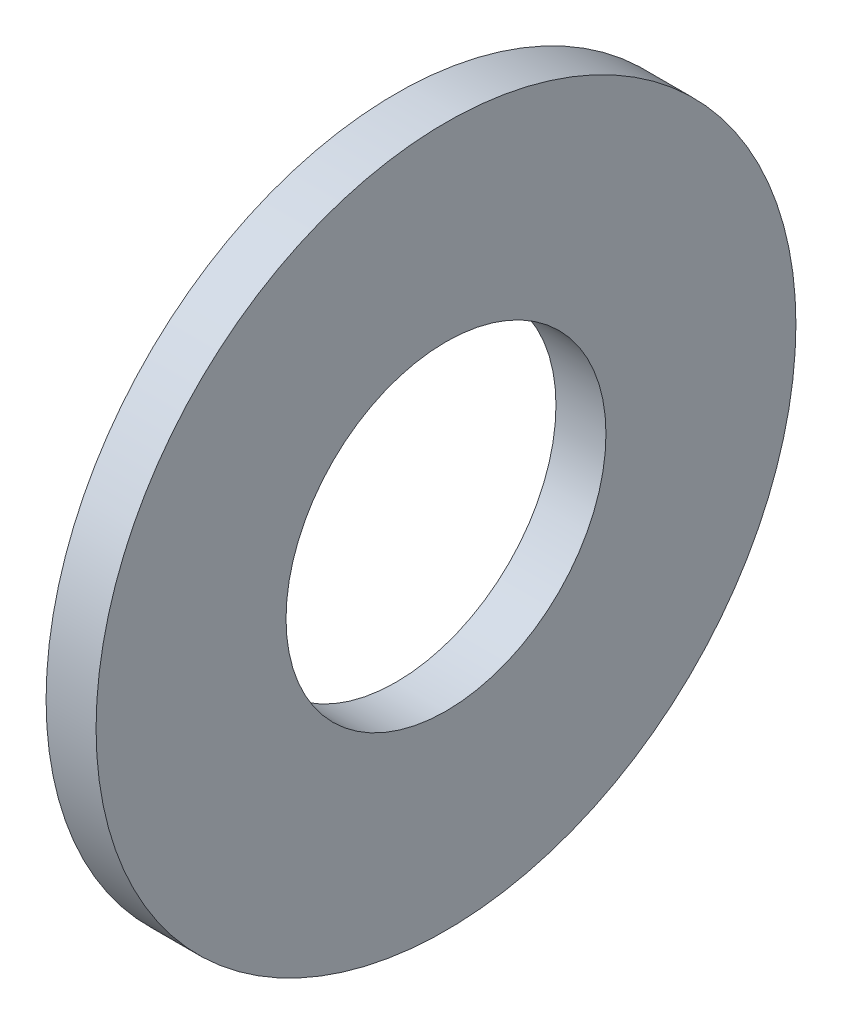
from build123d import *

# Parameters (mm, degrees)
SKETCH1_W = 0.5
SKETCH1_H = 1.9


with BuildPart() as part:
    # Sketch1 → Base-Revolve (revolve)
    with BuildSketch(Plane.XY):
        with Locations((-0.25, 2.55)):
            Rectangle(SKETCH1_W, SKETCH1_H)
    revolve(axis=Axis((-34.925, 0, 0), (1, 0, 0)))


solid = part.part
